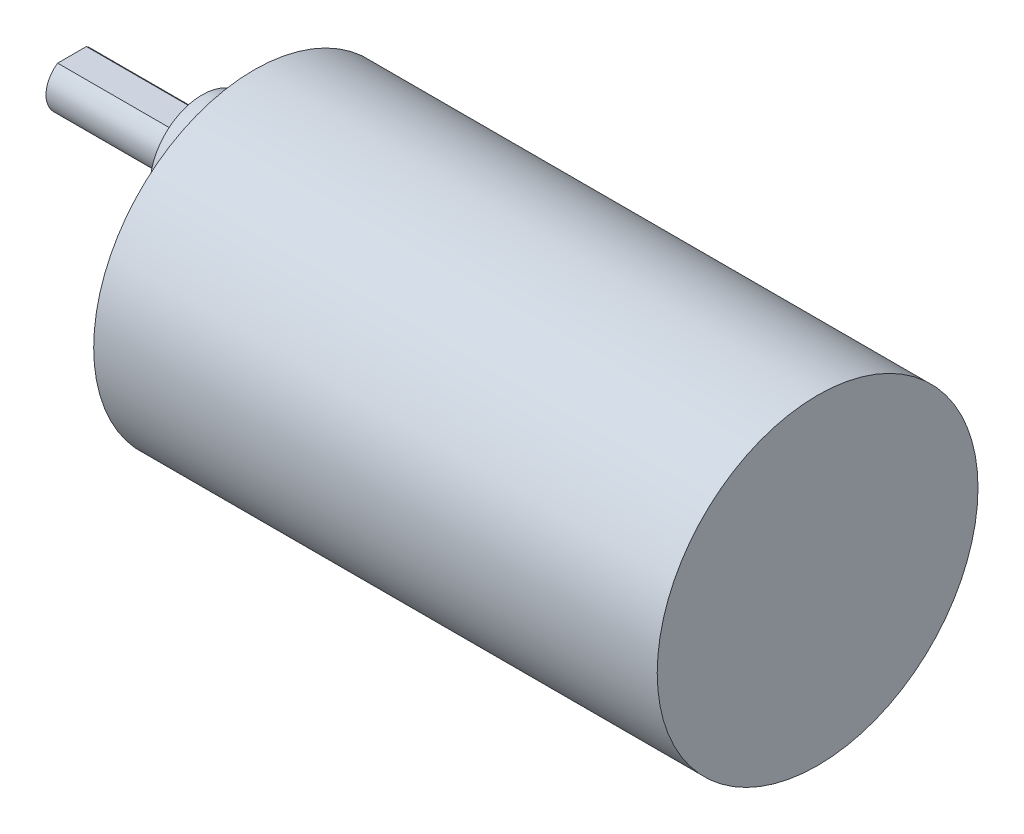
from build123d import *

# Parameters (mm, degrees)
SKIZZE1_R                       = 18.5
AUFSATZ_LINEAR_AUSTRAGEN1_DEPTH = 65
SKIZZE2_R                       = 6
AUFSATZ_LINEAR_AUSTRAGEN2_DEPTH = 6
AUFSATZ_LINEAR_AUSTRAGEN3_DEPTH = 15


with BuildPart() as part:
    # Skizze1 → Aufsatz-Linear austragen1 (new body)
    with BuildSketch(Plane(origin=(0, 0, 0), x_dir=(0, 0, -1), z_dir=(1, 0, 0))):
        Circle(SKIZZE1_R)
    extrude(amount=AUFSATZ_LINEAR_AUSTRAGEN1_DEPTH)

    # Skizze2 → Aufsatz-Linear austragen2 (add)
    with BuildSketch(Plane.ZY):
        with Locations((0, 7)):
            Circle(SKIZZE2_R)
    extrude(amount=AUFSATZ_LINEAR_AUSTRAGEN2_DEPTH)

    # Skizze3 → Aufsatz-Linear austragen3 (add)
    with BuildSketch(Plane.ZY.offset(6)):
        with BuildLine():
            Line((-1.658312395, 9.5), (1.658312395, 9.5))
            ThreePointArc((1.658312395, 9.5), (0, 4), (-1.658312395, 9.5))
        make_face()
    extrude(amount=AUFSATZ_LINEAR_AUSTRAGEN3_DEPTH)


solid = part.part
